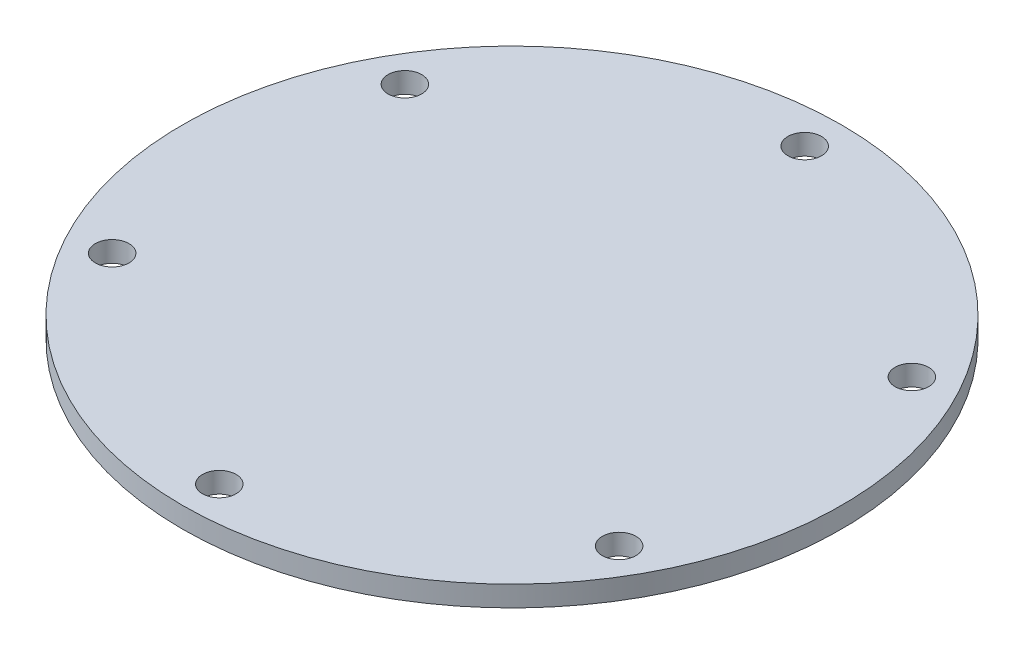
from build123d import *

# Parameters (mm, degrees)
SKETCH1_R                  = 50.8
BOSS_EXTRUDE1_DEPTH        = 3.175
F_6_0_204_DIAMETER_HOLE1_D = 5.1816
CIRPATTERN1_COUNT          = 6


with BuildPart() as part:
    # Sketch1 → Boss-Extrude1 (new body)
    with BuildSketch(Plane(origin=(0, 0, 0), x_dir=(1, 0, 0), z_dir=(0, 1, 0))):
        Circle(SKETCH1_R)
    extrude(amount=BOSS_EXTRUDE1_DEPTH)

    # #6 (0.204) Diameter Hole1 (through all)
    with Locations(Plane(origin=(0, 3.175, 0), x_dir=(1, 0, 0), z_dir=(0, 1, 0))):
        with Locations((0, 45.119902577)):
            f_6_0_204_diameter_hole1 = Hole(F_6_0_204_DIAMETER_HOLE1_D / 2)

    # CirPattern1: #6 (0.204) Diameter Hole1 ×6 about axis
    cirpattern1_axis = Axis((0, 0, 0), (0, 1, 0))
    for i in range(1, CIRPATTERN1_COUNT):
        add(f_6_0_204_diameter_hole1.rotate(cirpattern1_axis, i * 360 / CIRPATTERN1_COUNT), mode=Mode.SUBTRACT)


solid = part.part
